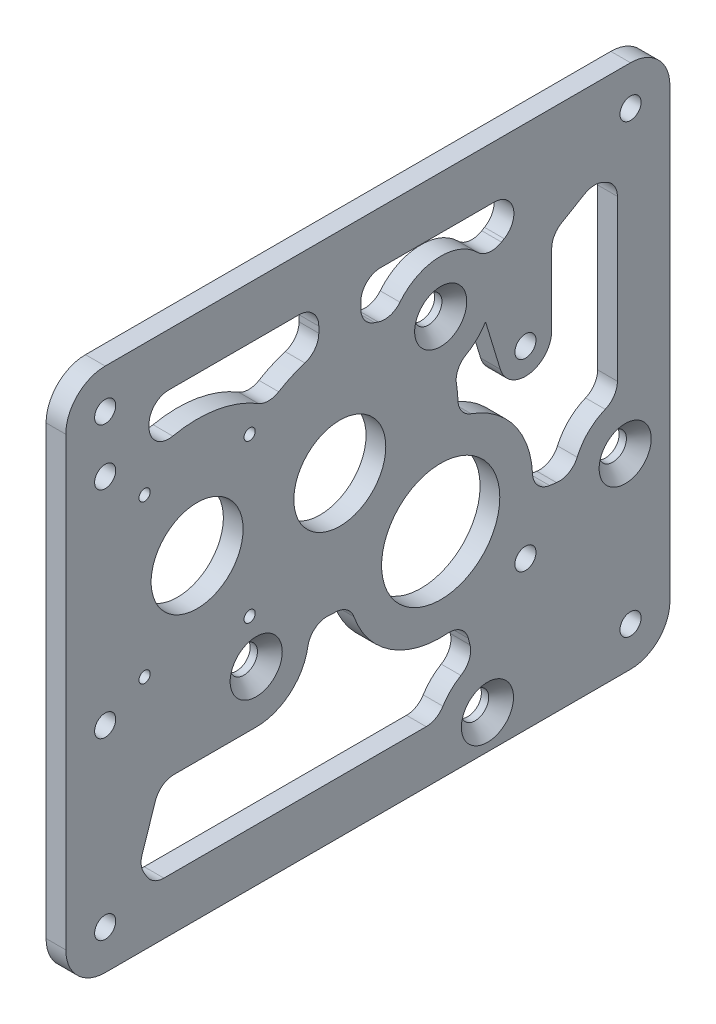
from build123d import *

# Parameters (mm, degrees)
SKETCH1_W                                      = 146.05
SKETCH1_H                                      = 127
BOSS_EXTRUDE2_DEPTH                            = 4.7625
SKETCH2_R                                      = 14.2875
SKETCH2_R_2                                    = 11.1125
CUT_EXTRUDE1_DEPTH                             = 5.7625
CSK_FOR_M6_FLAT_HEAD_MACHINE_SCREW1_AT_2_COUNT = 2
CSK_FOR_M6_FLAT_HEAD_MACHINE_SCREW1_AT_2_PITCH = 89.21849584
CSK_FOR_M6_FLAT_HEAD_MACHINE_SCREW1_AT_3_COUNT = 2
CSK_FOR_M6_FLAT_HEAD_MACHINE_SCREW1_AT_3_PITCH = 67.75071052
CSK_FOR_M6_FLAT_HEAD_MACHINE_SCREW1_AT_4_COUNT = 2
CSK_FOR_M6_FLAT_HEAD_MACHINE_SCREW1_AT_4_PITCH = 67.750719553
F_10_CLEARANCE_HOLE2_D                         = 5.1054
FILLET2_R                                      = 9.525
F_10_CLEARANCE_HOLE1_D                         = 5.1054
F_6_32_TAPPED_HOLE1_D                          = 2.7051
CUT_EXTRUDE2_DEPTH                             = 5.7625
FILLET28_R                                     = 4.7625


with BuildPart() as part:
    # Sketch1 → Boss-Extrude2 (new body)
    with BuildSketch(Plane(origin=(0, 0, 0), x_dir=(0, 0, -1), z_dir=(1, 0, 0))):
        with Locations((73.025, 63.5)):
            Rectangle(SKETCH1_W, SKETCH1_H)
    extrude(amount=BOSS_EXTRUDE2_DEPTH)

    # Sketch2 → Cut-Extrude1 (cut, through all)
    with BuildSketch(Plane(origin=(4.7625, 0, 0), x_dir=(0, 0, -1), z_dir=(1, 0, 0))):
        with Locations((90.633575625, 51.809624375)):
            Circle(SKETCH2_R)
        with Locations((31.75, 76.2)):
            Circle(SKETCH2_R_2)
        with Locations((66.2432, 76.2)):
            Circle(SKETCH2_R_2)
    extrude(amount=-CUT_EXTRUDE1_DEPTH, mode=Mode.SUBTRACT)

    # Sketch4 → CSK for M6 Flat Head Machine Screw1 (revolve, cut)
    with BuildSketch(Plane(origin=(4.7625, 96.809624375, -90.633575625), x_dir=(0, 0, -1), z_dir=(0, 1, 0))):
        Polygon((0, 0), (0, 4.7625), (3.3, 4.7625), (3.3, 3), (6.3, 0), align=None)
    csk_for_m6_flat_head_machine_screw1 = revolve(axis=Axis((11.1125, 96.809624375, -90.633575625), (-1, 0, 0)), mode=Mode.SUBTRACT)

    # CSK for M6 Flat Head Machine Screw1 at 2: CSK for M6 Flat Head Machine Screw1 ×2
    with Locations(*[Vector(0, -0.991946784, -0.126655352) * (i * CSK_FOR_M6_FLAT_HEAD_MACHINE_SCREW1_AT_2_PITCH) for i in range(1, CSK_FOR_M6_FLAT_HEAD_MACHINE_SCREW1_AT_2_COUNT)]):
        add(csk_for_m6_flat_head_machine_screw1, mode=Mode.SUBTRACT)

    # CSK for M6 Flat Head Machine Screw1 at 3: CSK for M6 Flat Head Machine Screw1 ×2
    with Locations(*[Vector(0, -0.752759456, 0.658295679) * (i * CSK_FOR_M6_FLAT_HEAD_MACHINE_SCREW1_AT_3_PITCH) for i in range(1, CSK_FOR_M6_FLAT_HEAD_MACHINE_SCREW1_AT_3_COUNT)]):
        add(csk_for_m6_flat_head_machine_screw1, mode=Mode.SUBTRACT)

    # CSK for M6 Flat Head Machine Screw1 at 4: CSK for M6 Flat Head Machine Screw1 ×2
    with Locations(*[Vector(0, -0.752759533, -0.658295591) * (i * CSK_FOR_M6_FLAT_HEAD_MACHINE_SCREW1_AT_4_PITCH) for i in range(1, CSK_FOR_M6_FLAT_HEAD_MACHINE_SCREW1_AT_4_COUNT)]):
        add(csk_for_m6_flat_head_machine_screw1, mode=Mode.SUBTRACT)

    # #10 Clearance Hole2 (through all)
    with Locations(Plane(origin=(4.7625, 0, 0), x_dir=(0, 0, -1), z_dir=(1, 0, 0))):
        with Locations((111.125, 35.934624375), (9.525, 103.879624375), (111.125, 80.384624375), (9.525, 51.809624375)):
            Hole(F_10_CLEARANCE_HOLE2_D / 2)

    # Fillet2
    fillet2_edges = [part.edges().sort_by_distance(p)[0] for p in [
        (2.38125, 127, 0),
        (2.38125, 127, -146.05),
        (2.38125, 0, -146.05),
        (2.38125, 0, 0),
    ]]
    fillet(fillet2_edges, radius=FILLET2_R)

    # #10 Clearance Hole1 (through all)
    with Locations(Plane(origin=(4.7625, 0, 0), x_dir=(0, 0, -1), z_dir=(1, 0, 0))):
        with Locations((9.525, 9.525), (136.525, 117.475), (9.525, 117.475), (136.525, 9.525)):
            Hole(F_10_CLEARANCE_HOLE1_D / 2)

    # #6-32 Tapped Hole1 (through all)
    with Locations(Plane.ZY):
        with Locations((-31.75, 76.2), (-19.05, 57.15), (-44.45, 57.15), (-44.45, 95.25), (-19.05, 95.25)):
            Hole(F_6_32_TAPPED_HOLE1_D / 2)

    # Sketch11 → Cut-Extrude2 (cut, through all)
    with BuildSketch(Plane(origin=(4.7625, 0, 0), x_dir=(0, 0, -1), z_dir=(1, 0, 0))):
        with BuildLine():
            Line((20.125750719, 114.3), (61.1632, 114.3))
            Line((61.1632, 114.3), (61.1632, 104.319819078))
            ThreePointArc((61.1632, 104.319819078), (54.765461277, 102.368533371), (48.9966, 98.98344604))
            ThreePointArc((48.9966, 98.98344604), (35.014791759, 104.587880509), (20.125750719, 102.303782363))
            Line((20.125750719, 102.303782363), (20.125750719, 114.3))
        make_face()
        with BuildLine():
            Line((121.087253606, 114.3), (101.709889704, 102.920088059))
            ThreePointArc((101.709889704, 102.920088059), (89.994334863, 109.443462717), (78.997060348, 101.770875449))
            ThreePointArc((78.997060348, 101.770875449), (75.250748065, 103.318161864), (71.3232, 104.319819078))
            Line((71.3232, 104.319819078), (71.3232, 114.3))
            Line((71.3232, 114.3), (121.087253606, 114.3))
        make_face()
        with BuildLine():
            Line((127.631878112, 106.361000738), (117.475, 100.396083162))
            Line((117.475, 100.396083162), (117.475, 80.384624375))
            ThreePointArc((117.475, 80.384624375), (112.058293757, 74.103584432), (105.049342437, 78.538307725))
            Line((105.049342437, 78.538307725), (101.476790239, 90.294473047))
            ThreePointArc((101.476790239, 90.294473047), (98.112436221, 86.607215631), (93.583659035, 84.508424927))
            ThreePointArc((93.583659035, 84.508424927), (94.666814629, 79.137474501), (94.704955629, 73.658525717))
            ThreePointArc((94.704955629, 73.658525717), (108.638744313, 64.838996021), (112.660149901, 48.846408105))
            Line((112.660149901, 48.846408105), (122.696515351, 47.496224412))
            ThreePointArc((122.696515351, 47.496224412), (126.218606107, 54.683903196), (133.35, 58.318606862))
            Line((133.35, 58.318606862), (133.35, 103.599555088))
            Line((133.35, 103.599555088), (127.631878112, 106.361000738))
        make_face()
        with BuildLine():
            Line((21.01489939, 12.7), (90.069887249, 12.7))
            ThreePointArc((90.069887249, 12.7), (93.448260094, 17.69162418), (98.753043882, 20.553264268))
            Line((98.753043882, 20.553264268), (96.221505899, 30.298565353))
            ThreePointArc((96.221505899, 30.298565353), (78.711310904, 33.053019434), (68.784674283, 47.738244371))
            ThreePointArc((68.784674283, 47.738244371), (63.515738278, 47.755464891), (58.339535779, 48.739797581))
            ThreePointArc((58.339535779, 48.739797581), (55.960534859, 37.96884685), (46.033575625, 33.159636375))
            Line((46.033575625, 33.159636375), (22.758002296, 33.159636375))
            Line((22.758002296, 33.159636375), (17.754472631, 18.14904738))
            Line((17.754472631, 18.14904738), (21.01489939, 12.7))
        make_face()
    extrude(amount=-CUT_EXTRUDE2_DEPTH, mode=Mode.SUBTRACT)

    # Fillet28
    fillet28_edges = [part.edges().sort_by_distance(p)[0] for p in [
        (2.38125, 20.553264268, -98.753043882),
        (2.38125, 12.7, -90.069887249),
        (2.38125, 12.7, -21.01489939),
        (2.38125, 18.14904738, -17.754472631),
        (2.38125, 33.159636375, -22.758002296),
        (2.38125, 48.739797581, -58.339535779),
        (2.38125, 47.738244371, -68.784674283),
        (2.38125, 30.298565353, -96.221505899),
        (2.38125, 102.303782363, -20.125750719),
        (2.38125, 114.3, -20.125750719),
        (2.38125, 114.3, -61.1632),
        (2.38125, 104.319819078, -61.1632),
        (2.38125, 98.98344604, -48.9966),
        (2.38125, 101.770875449, -78.997060348),
        (2.38125, 104.319819078, -71.3232),
        (2.38125, 114.3, -71.3232),
        (2.38125, 114.3, -121.087253606),
        (2.38125, 102.920088059, -101.709889704),
        (2.38125, 100.396083162, -117.475),
        (2.38125, 106.361000738, -127.631878112),
        (2.38125, 103.599555088, -133.35),
        (2.38125, 58.318606862, -133.35),
        (2.38125, 47.496224412, -122.696515351),
        (2.38125, 48.846408105, -112.660149901),
        (2.38125, 73.658525717, -94.704955629),
        (2.38125, 84.508424927, -93.583659035),
    ]]
    fillet(fillet28_edges, radius=FILLET28_R)


solid = part.part
